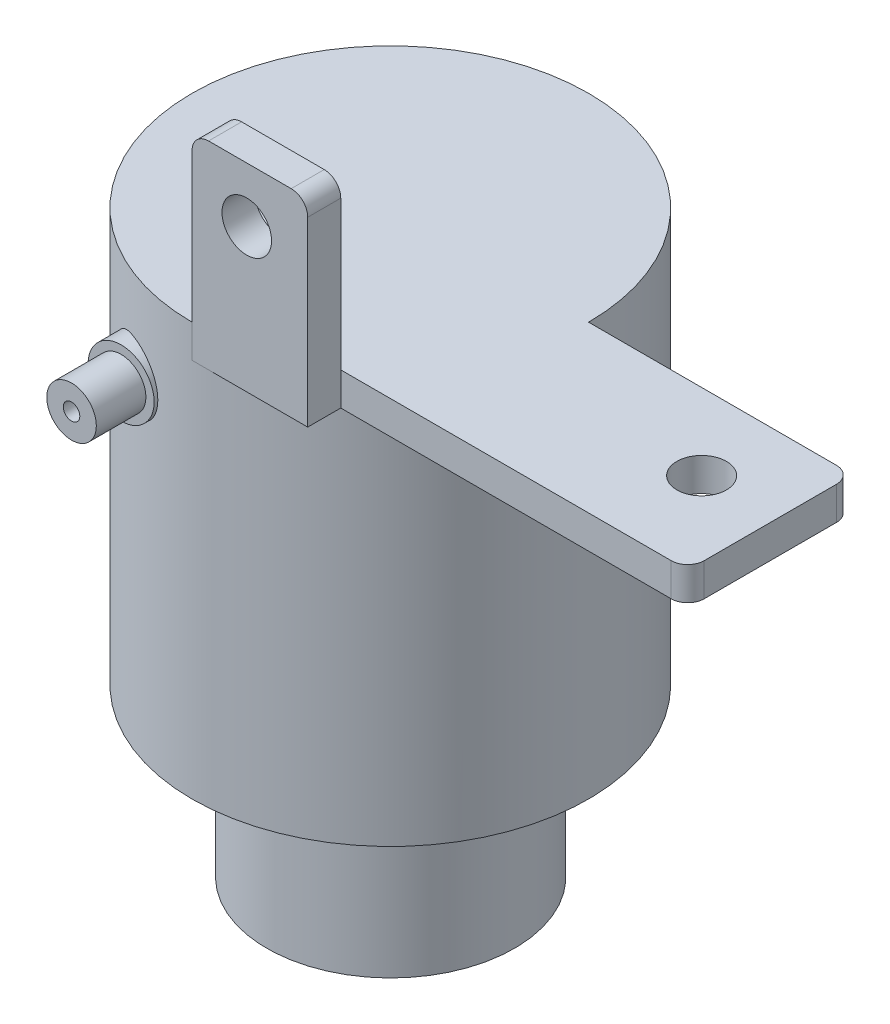
from build123d import *

# Parameters (mm, degrees)
CROQUIS1_W                   = 28
CROQUIS1_H                   = 10
SALIENTE_EXTRUIR1_DEPTH      = 2
CROQUIS5_W                   = 7
CROQUIS5_H                   = 12
SALIENTE_EXTRUIR5_DEPTH      = 2
SALIENTE_EXTRUIR6_DEPTH      = 2
SALIENTE_EXTRUIR6_DEPTH_BACK = 23
CROQUIS6_R                   = 12
CROQUIS9_R                   = 7.5
SALIENTE_EXTRUIR7_DEPTH      = 10
CROQUIS10_R                  = 6
CORTAR_EXTRUIR3_DEPTH        = 33
REDONDEO2_R                  = 1
REDONDEO3_R                  = 1
REDONDEO4_R                  = 1
REDONDEO5_R                  = 1
CROQUIS12_R                  = 1.5
CORTAR_EXTRUIR4_DEPTH        = 2
CROQUIS13_R                  = 1.5
CORTAR_EXTRUIR7_DEPTH        = 2
CROQUIS16_R                  = 2
SALIENTE_EXTRUIR9_DEPTH      = 2
CROQUIS17_R                  = 1.5
SALIENTE_EXTRUIR10_DEPTH     = 5
CROQUIS18_R                  = 0.5
CORTAR_EXTRUIR8_DEPTH        = 5
ESCALA1_SCALE                = 7


with BuildPart() as part:
    # Croquis1 → Saliente-Extruir1 (new body)
    with BuildSketch(Plane(origin=(0, 0, 0), x_dir=(1, 0, 0), z_dir=(0, 1, 0))):
        with Locations((14, 5)):
            Rectangle(CROQUIS1_W, CROQUIS1_H)
    extrude(amount=SALIENTE_EXTRUIR1_DEPTH)

    # Croquis5 → Saliente-Extruir5 (add)
    with BuildSketch(Plane.XY):
        with Locations((3.5, 6)):
            Rectangle(CROQUIS5_W, CROQUIS5_H)
    extrude(amount=SALIENTE_EXTRUIR5_DEPTH)

    # Croquis6 → Saliente-Extruir6 (add, two sides: drawn at the far end of the back side and taken through both)
    with BuildSketch(Plane(origin=(0, 0, 0), x_dir=(1, 0, 0), z_dir=(0, 1, 0)).offset(-SALIENTE_EXTRUIR6_DEPTH_BACK)):
        with Locations((0, 10)):
            Circle(CROQUIS6_R)
    extrude(amount=SALIENTE_EXTRUIR6_DEPTH + SALIENTE_EXTRUIR6_DEPTH_BACK)

    # Croquis9 → Saliente-Extruir7 (add)
    with BuildSketch(Plane(origin=(0, -23, 0), x_dir=(-1, 0, 0), z_dir=(0, -1, 0))):
        with Locations((-0.08521531, 9.936088517)):
            Circle(CROQUIS9_R)
    extrude(amount=SALIENTE_EXTRUIR7_DEPTH)

    # Croquis10 → Cortar-Extruir3 (cut)
    with BuildSketch(Plane.XZ.offset(33)):
        with Locations((0.08521531, -9.936088517)):
            Circle(CROQUIS10_R)
    extrude(amount=-CORTAR_EXTRUIR3_DEPTH, mode=Mode.SUBTRACT)

    # Redondeo2
    redondeo2_edges = [part.edges().sort_by_distance(p)[0] for p in [
        (28, 1, -10),
    ]]
    fillet(redondeo2_edges, radius=REDONDEO2_R)

    # Redondeo3
    redondeo3_edges = [part.edges().sort_by_distance(p)[0] for p in [
        (28, 1, 0),
    ]]
    fillet(redondeo3_edges, radius=REDONDEO3_R)

    # Redondeo4
    redondeo4_edges = [part.edges().sort_by_distance(p)[0] for p in [
        (7, 12, 1),
    ]]
    fillet(redondeo4_edges, radius=REDONDEO4_R)

    # Redondeo5
    redondeo5_edges = [part.edges().sort_by_distance(p)[0] for p in [
        (0, 12, 1),
    ]]
    fillet(redondeo5_edges, radius=REDONDEO5_R)

    # Croquis12 → Cortar-Extruir4 (cut)
    with BuildSketch(Plane.XY):
        with Locations((3.310400977, 8.667805531)):
            Circle(CROQUIS12_R)
    extrude(amount=CORTAR_EXTRUIR4_DEPTH, mode=Mode.SUBTRACT)

    # Croquis13 → Cortar-Extruir7 (cut)
    with BuildSketch(Plane(origin=(0, 0, 0), x_dir=(1, 0, 0), z_dir=(0, 1, 0))):
        with Locations((23.466578788, 5.377069426)):
            Circle(CROQUIS13_R)
    extrude(amount=CORTAR_EXTRUIR7_DEPTH, mode=Mode.SUBTRACT)

    # Croquis16 → Saliente-Extruir9 (add)
    with BuildSketch(Plane.XY):
        with Locations((-4.295016908, -3.333173785)):
            Circle(CROQUIS16_R)
    extrude(amount=SALIENTE_EXTRUIR9_DEPTH)

    # Croquis17 → Saliente-Extruir10 (add)
    with BuildSketch(Plane.XY):
        with Locations((-4.295016908, -3.333173785)):
            Circle(CROQUIS17_R)
    extrude(amount=SALIENTE_EXTRUIR10_DEPTH)

    # Croquis18 → Cortar-Extruir8 (cut)
    with BuildSketch(Plane.XY):
        with Locations((-4.295016908, -3.333173785)):
            Circle(CROQUIS18_R)
    extrude(amount=CORTAR_EXTRUIR8_DEPTH, mode=Mode.SUBTRACT)


with BuildPart() as part_1:
    # Escala1: scaled about (0.668234769, -10.721798359, -9.644957582)
    add(part.part.scale(ESCALA1_SCALE).moved(Location((-4.009408614, 64.330790154, 57.869745492))))


solid = part_1.part
